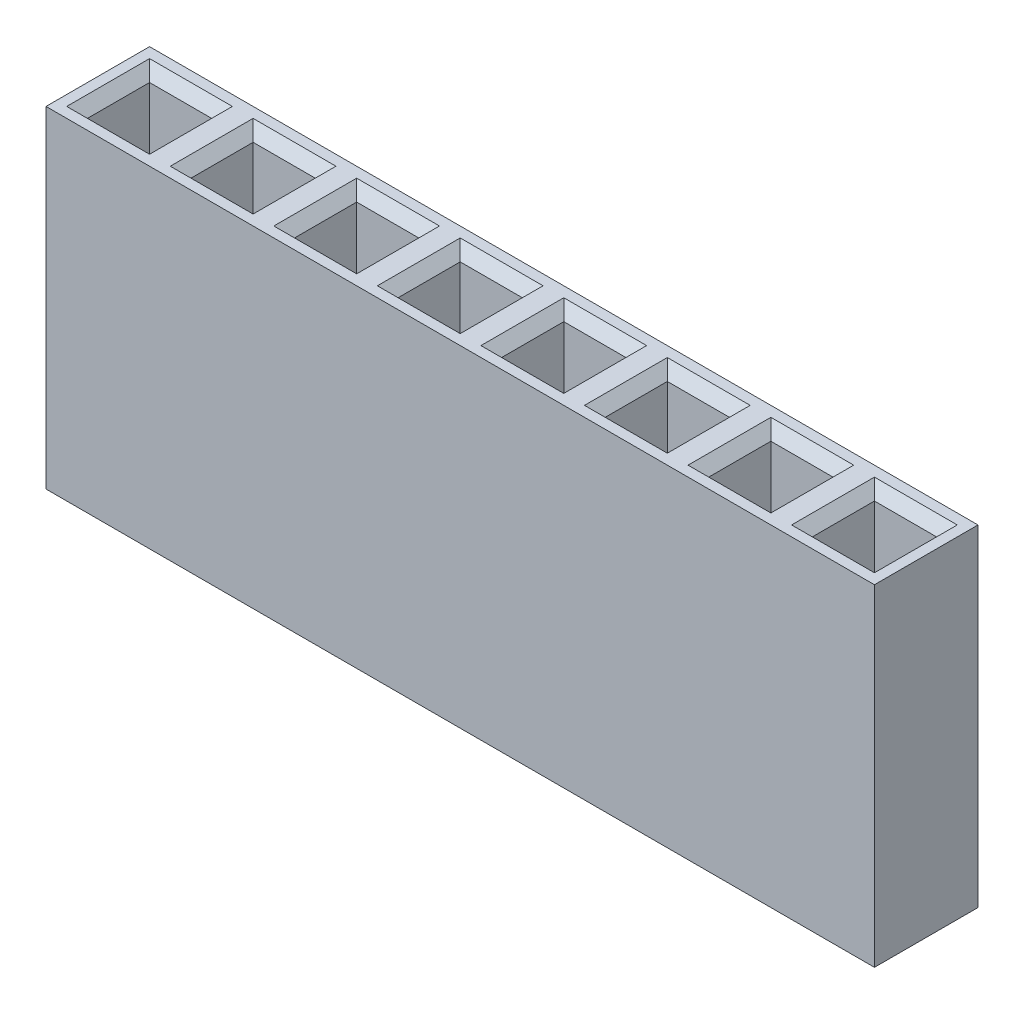
from build123d import *

# Parameters (mm, degrees)
SKETCH1_W                  = 2.5
SKETCH1_H                  = 8
BOSS_EXTRUDE1_DEPTH        = 2.5
SKETCH2_W                  = 1.5
SKETCH2_H                  = 1.5
CUT_EXTRUDE2_DEPTH         = 7
CHAMFER3_SIZE              = 0.25
LPATTERN2_COUNT            = 8
LPATTERN2_PITCH            = 2.5
CHAMFER3_OF_LPATTERN2_SIZE = 0.25


with BuildPart() as part:
    # Sketch1 → Boss-Extrude1 (new body)
    with BuildSketch(Plane.XY):
        Rectangle(SKETCH1_W, SKETCH1_H)
    boss_extrude1 = extrude(amount=BOSS_EXTRUDE1_DEPTH)

    # Sketch2 → Cut-Extrude2 (cut)
    with BuildSketch(Plane(origin=(0, 4, 0), x_dir=(1, 0, 0), z_dir=(0, 1, 0))):
        with Locations((0, -1.25)):
            Rectangle(SKETCH2_W, SKETCH2_H)
    cut_extrude2 = extrude(amount=-CUT_EXTRUDE2_DEPTH, mode=Mode.SUBTRACT)

    # Chamfer3
    chamfer3_edges = [part.edges().sort_by_distance(p)[0] for p in [
        (0, 4, 2),
        (0.75, 4, 1.25),
        (0, 4, 0.5),
        (-0.75, 4, 1.25),
    ]]
    chamfer(chamfer3_edges, length=CHAMFER3_SIZE)

    # LPattern2: Boss-Extrude1, Cut-Extrude2 ×8
    with Locations(*[(i * LPATTERN2_PITCH, 0, 0) for i in range(1, LPATTERN2_COUNT)]):
        add(boss_extrude1)
        add(cut_extrude2, mode=Mode.SUBTRACT)

    # Chamfer3 of LPattern2
    chamfer3_of_lpattern2_edges = [part.edges().sort_by_distance(p)[0] for p in [
        (2.5, 4, 2),
        (3.25, 4, 1.25),
        (2.5, 4, 0.5),
        (1.75, 4, 1.25),
        (5, 4, 2),
        (5.75, 4, 1.25),
        (5, 4, 0.5),
        (4.25, 4, 1.25),
        (7.5, 4, 2),
        (8.25, 4, 1.25),
        (7.5, 4, 0.5),
        (6.75, 4, 1.25),
        (10, 4, 2),
        (10.75, 4, 1.25),
        (10, 4, 0.5),
        (9.25, 4, 1.25),
        (12.5, 4, 2),
        (13.25, 4, 1.25),
        (12.5, 4, 0.5),
        (11.75, 4, 1.25),
        (15, 4, 2),
        (15.75, 4, 1.25),
        (15, 4, 0.5),
        (14.25, 4, 1.25),
        (17.5, 4, 2),
        (18.25, 4, 1.25),
        (17.5, 4, 0.5),
        (16.75, 4, 1.25),
    ]]
    chamfer(chamfer3_of_lpattern2_edges, length=CHAMFER3_OF_LPATTERN2_SIZE)


solid = part.part
